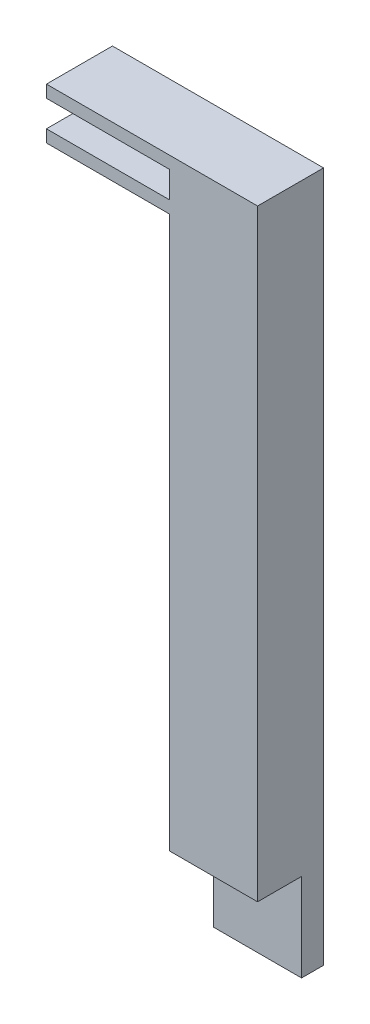
from build123d import *

# Parameters (mm, degrees)
BOSS_EXTRUDE1_DEPTH = 25.4
SKETCH2_W           = 63.5
SKETCH2_H           = 25.4
CUT_EXTRUDE1_DEPTH  = 19.05
SKETCH3_R           = 15.875
CUT_EXTRUDE4_DEPTH  = 26.4
SKETCH5_R           = 22.225
SKETCH5_R_2         = 15.875
CUT_EXTRUDE6_DEPTH  = 19.05
SKETCH6_R           = 12.7
CUT_EXTRUDE7_DEPTH  = 3.175
BOSS_EXTRUDE2_DEPTH = 25.4
SKETCH9_W           = 19.05
SKETCH9_H           = 3.556
BOSS_EXTRUDE4_DEPTH = 35.56


with BuildPart() as part:
    # Sketch1 → Boss-Extrude1 (new body)
    with BuildSketch(Plane.XY):
        with BuildLine():
            Line((-19.05, -66.675), (-19.05, -76.2))
            Line((-19.05, -76.2), (19.05, -76.2))
            Line((19.05, -76.2), (19.05, -66.675))
            ThreePointArc((19.05, -66.675), (16.80493597, -61.25493597), (22.225, -63.5))
            Line((22.225, -63.5), (31.75, -63.5))
            Line((31.75, -63.5), (31.75, 63.5))
            Line((31.75, 63.5), (22.225, 63.5))
            ThreePointArc((22.225, 63.5), (16.80493597, 61.25493597), (19.05, 66.675))
            Line((19.05, 66.675), (19.05, 76.2))
            Line((19.05, 76.2), (-19.05, 76.2))
            Line((-19.05, 76.2), (-19.05, 66.675))
            ThreePointArc((-19.05, 66.675), (-16.80493597, 65.74506403), (-15.875, 63.5))
            ThreePointArc((-15.875, 63.5), (-19.05, 60.325), (-22.225, 63.5))
            Line((-22.225, 63.5), (-31.75, 63.5))
            Line((-31.75, 63.5), (-31.75, -63.5))
            Line((-31.75, -63.5), (-22.225, -63.5))
            ThreePointArc((-22.225, -63.5), (-19.05, -60.325), (-15.875, -63.5))
            ThreePointArc((-15.875, -63.5), (-16.80493597, -65.74506403), (-19.05, -66.675))
        make_face()
        with BuildLine():
            Line((-31.75, 76.2), (-31.75, 63.5))
            Line((-31.75, 63.5), (-22.225, 63.5))
            ThreePointArc((-22.225, 63.5), (-21.29506403, 65.74506403), (-19.05, 66.675))
            Line((-19.05, 66.675), (-19.05, 76.2))
            Line((-19.05, 76.2), (-31.75, 76.2))
        make_face()
        with BuildLine():
            Line((22.225, 63.5), (31.75, 63.5))
            Line((31.75, 63.5), (31.75, 76.2))
            Line((31.75, 76.2), (19.05, 76.2))
            Line((19.05, 76.2), (19.05, 66.675))
            ThreePointArc((19.05, 66.675), (21.29506403, 65.74506403), (22.225, 63.5))
        make_face()
        with BuildLine():
            Line((-31.75, -63.5), (-31.75, -76.2))
            Line((-31.75, -76.2), (-19.05, -76.2))
            Line((-19.05, -76.2), (-19.05, -66.675))
            ThreePointArc((-19.05, -66.675), (-21.29506403, -65.74506403), (-22.225, -63.5))
            Line((-22.225, -63.5), (-31.75, -63.5))
        make_face()
        with BuildLine():
            Line((19.05, -66.675), (19.05, -76.2))
            Line((19.05, -76.2), (31.75, -76.2))
            Line((31.75, -76.2), (31.75, -63.5))
            Line((31.75, -63.5), (22.225, -63.5))
            ThreePointArc((22.225, -63.5), (21.29506403, -65.74506403), (19.05, -66.675))
        make_face()
    extrude(amount=BOSS_EXTRUDE1_DEPTH)

    # Sketch2 → Cut-Extrude1 (cut)
    with BuildSketch(Plane.XY.offset(25.4)):
        with Locations((0, 63.5)):
            Rectangle(SKETCH2_W, SKETCH2_H)
        with Locations((0, -63.5)):
            Rectangle(SKETCH2_W, SKETCH2_H)
    extrude(amount=-CUT_EXTRUDE1_DEPTH, mode=Mode.SUBTRACT)

    # Sketch3 → Cut-Extrude4 (cut, through all)
    with BuildSketch(Plane.XY.offset(25.4)):
        Circle(SKETCH3_R)
    extrude(amount=-CUT_EXTRUDE4_DEPTH, mode=Mode.SUBTRACT)

    # Sketch5 → Cut-Extrude6 (cut)
    with BuildSketch(Plane.XY.offset(25.4)):
        Circle(SKETCH5_R)
        Circle(SKETCH5_R_2, mode=Mode.SUBTRACT)
    extrude(amount=-CUT_EXTRUDE6_DEPTH, mode=Mode.SUBTRACT)

    # Sketch6 → Cut-Extrude7 (cut)
    with BuildSketch(Plane.XY.offset(25.4)):
        with Locations((0, -50.8)):
            Circle(SKETCH6_R)
        with Locations((0, 50.8)):
            Circle(SKETCH6_R)
    extrude(amount=-CUT_EXTRUDE7_DEPTH, mode=Mode.SUBTRACT)


with BuildPart() as body_2:
    # Sketch7 → Boss-Extrude2 (new body)
    with BuildSketch(Plane.ZY.offset(31.75)):
        Polygon((0, 123.19), (19.05, 123.19), (19.05, -50.8), (6.35, -50.8), (6.35, -76.2), (0, -76.2), align=None)
    extrude(amount=BOSS_EXTRUDE2_DEPTH)

    # Sketch9 → Boss-Extrude4 (add)
    with BuildSketch(Plane.ZY.offset(57.15)):
        with Locations((9.525, 121.412)):
            Rectangle(SKETCH9_W, SKETCH9_H)
        with Locations((9.525, 110.236)):
            Rectangle(SKETCH9_W, SKETCH9_H)
    extrude(amount=BOSS_EXTRUDE4_DEPTH)


solid = body_2.part
